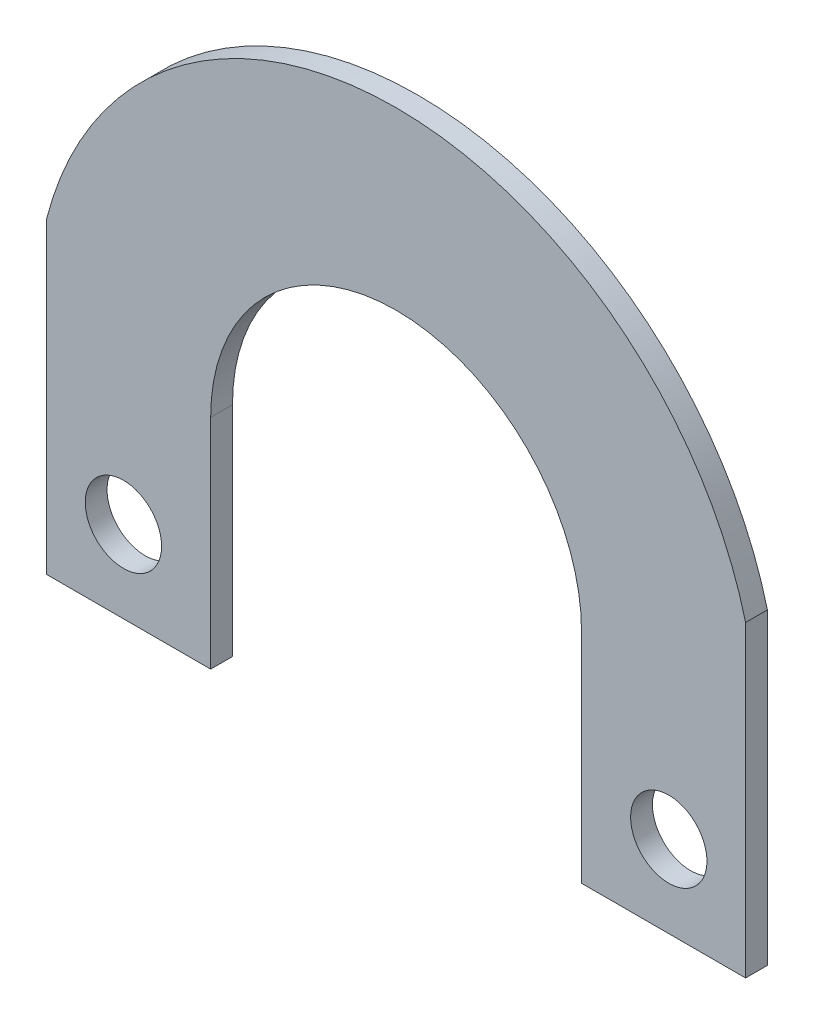
from build123d import *

# Parameters (mm, degrees)
SKETCH1_R           = 3.5
BOSS_EXTRUDE1_DEPTH = 2


with BuildPart() as part:
    # Sketch1 → Boss-Extrude1 (new body)
    with BuildSketch(Plane.XY):
        with BuildLine():
            Line((-17.5, -20), (-32.04293994, -20))
            Line((-32.04293994, -20), (-32.04293994, 8.228064973))
            ThreePointArc((-32.04293994, 8.228064973), (0, 33.082488619), (32.04293994, 8.228064973))
            Line((32.04293994, 8.228064973), (32.04293994, -20))
            Line((32.04293994, -20), (17.5, -20))
            Line((17.5, -20), (17, -20))
            Line((17, -20), (17, 0))
            ThreePointArc((17, 0), (0, 17), (-17, 0))
            Line((-17, 0), (-17, -20))
            Line((-17, -20), (-17.5, -20))
        make_face()
        with Locations((-25, -12.5)):
            Circle(SKETCH1_R, mode=Mode.SUBTRACT)
        with Locations((25, -12.5)):
            Circle(SKETCH1_R, mode=Mode.SUBTRACT)
    extrude(amount=BOSS_EXTRUDE1_DEPTH)


solid = part.part
